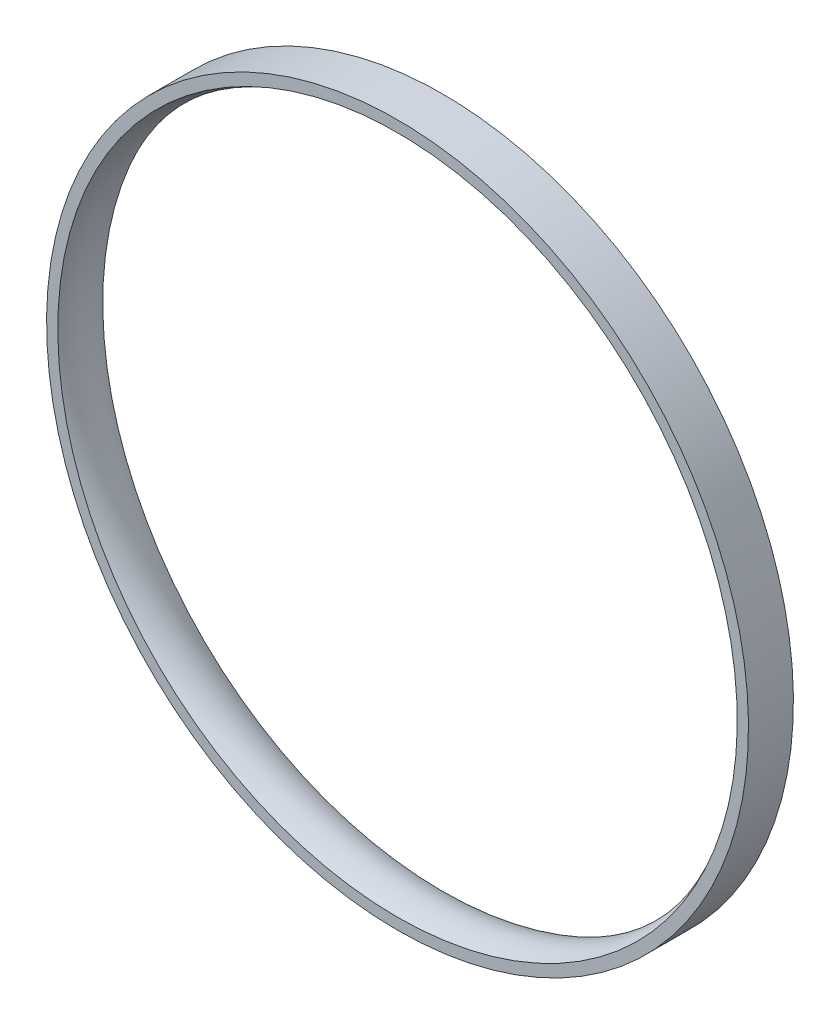
from build123d import *


with BuildPart() as part:
    # Balayage1: sweep along a path in Esquisse1
    with BuildLine(Plane.XY) as balayage1_path:
        CenterArc((0, 0), 156.15, 0, 360)
    # Esquisse2 → Balayage1 (sweep)
    with BuildSketch(Plane(origin=(0, 0, 0), x_dir=(0, 0, -1), z_dir=(1, 0, 0))):
        with BuildLine():
            Line((-10, -156.15), (10, -156.15))
            Line((10, -156.15), (10, -151.15))
            ThreePointArc((10, -151.15), (0, -148.470508076), (-10, -151.15))
            Line((-10, -151.15), (-10, -156.15))
        make_face()
    sweep(path=balayage1_path.line)


solid = part.part
